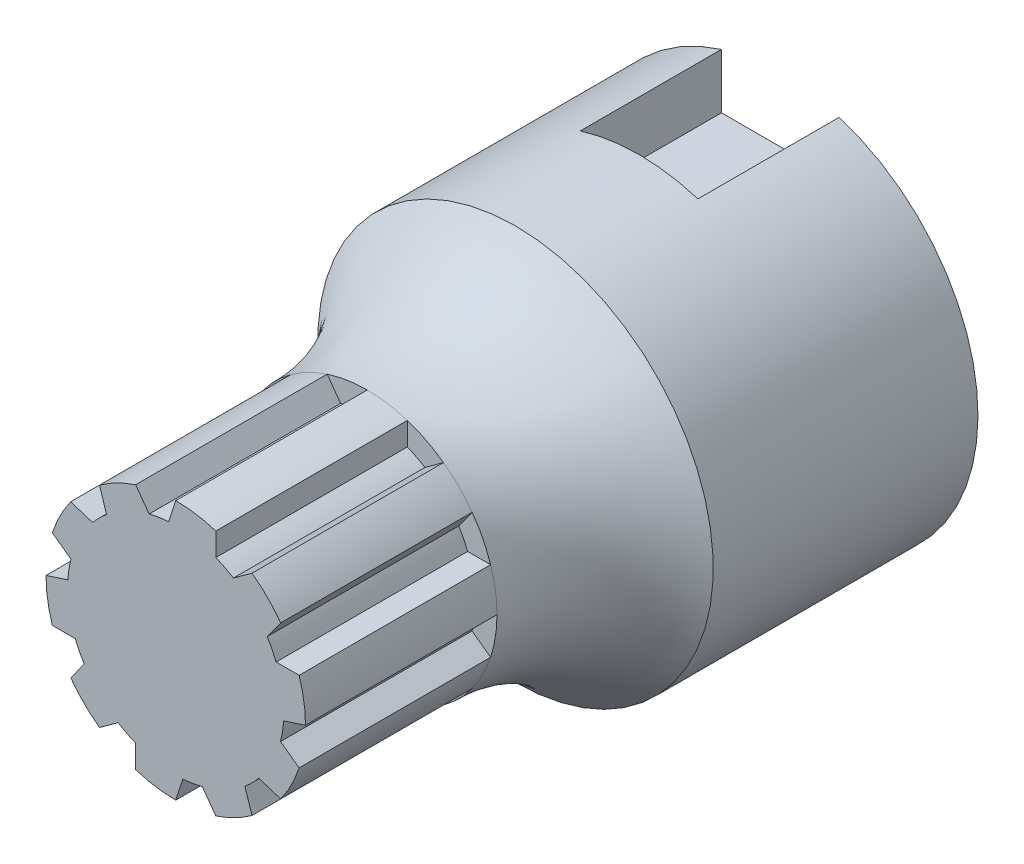
from build123d import *

# Parameters (mm, degrees)
BOSS_EXTRUDE1_DEPTH = 20
CIRPATTERN1_COUNT   = 10
CUT_EXTRUDE1_START  = -11.43
SKETCH3_W           = 9.525
SKETCH3_H           = 5.618681597
CUT_EXTRUDE1_DEPTH  = 11.43


with BuildPart() as part:
    # Sketch1 → Boss-Extrude1 (new body)
    with BuildSketch(Plane.XY):
        with BuildLine():
            Line((0, 10.5), (0, 0))
            Line((0, 0), (6.171745149, 8.494678441))
            Line((6.171745149, 8.494678441), (4.667031658, 7.401440097))
            ThreePointArc((4.667031658, 7.401440097), (3.972416873, 7.796307087), (3.244678441, 8.126165259))
            Line((3.244678441, 8.126165259), (3.244678441, 9.986093421))
            ThreePointArc((3.244678441, 9.986093421), (1.642561883, 10.370727576), (0, 10.5))
        make_face()
    boss_extrude1 = extrude(amount=-BOSS_EXTRUDE1_DEPTH)

    # CirPattern1: Boss-Extrude1 ×10 about axis
    cirpattern1_axis = Axis((0, 0, 0), (0, 0, 1))
    for i in range(1, CIRPATTERN1_COUNT):
        add(boss_extrude1.rotate(cirpattern1_axis, i * 360 / CIRPATTERN1_COUNT))

    # Sketch2 → Revolve1 (revolve)
    with BuildSketch(Plane(origin=(0, 0, 0), x_dir=(0, 0, -1), z_dir=(1, 0, 0))):
        with BuildLine():
            Line((2.355087252, 0), (2.355087252, 8.6))
            Line((2.355087252, 8.6), (15.5, 8.6))
            Line((15.5, 8.6), (15.5, 10.5))
            ThreePointArc((15.5, 10.5), (22.100189391, 11.940495874), (27.5, 16))
            Line((27.5, 16), (48.93, 16))
            Line((48.93, 16), (48.93, 0))
            Line((48.93, 0), (2.355087252, 0))
        make_face()
    revolve(axis=Axis((0, 0, -48.93), (0, 0, 1)))

    # Sketch3 → Cut-Extrude1 (cut)
    with BuildSketch(Plane(origin=(0, 0, -48.93), x_dir=(-1, 0, 0), z_dir=(0, 0, -1)).offset(CUT_EXTRUDE1_START)):
        with Locations((0, 13.639110642)):
            Rectangle(SKETCH3_W, SKETCH3_H)
    extrude(amount=CUT_EXTRUDE1_DEPTH, mode=Mode.SUBTRACT)


solid = part.part
